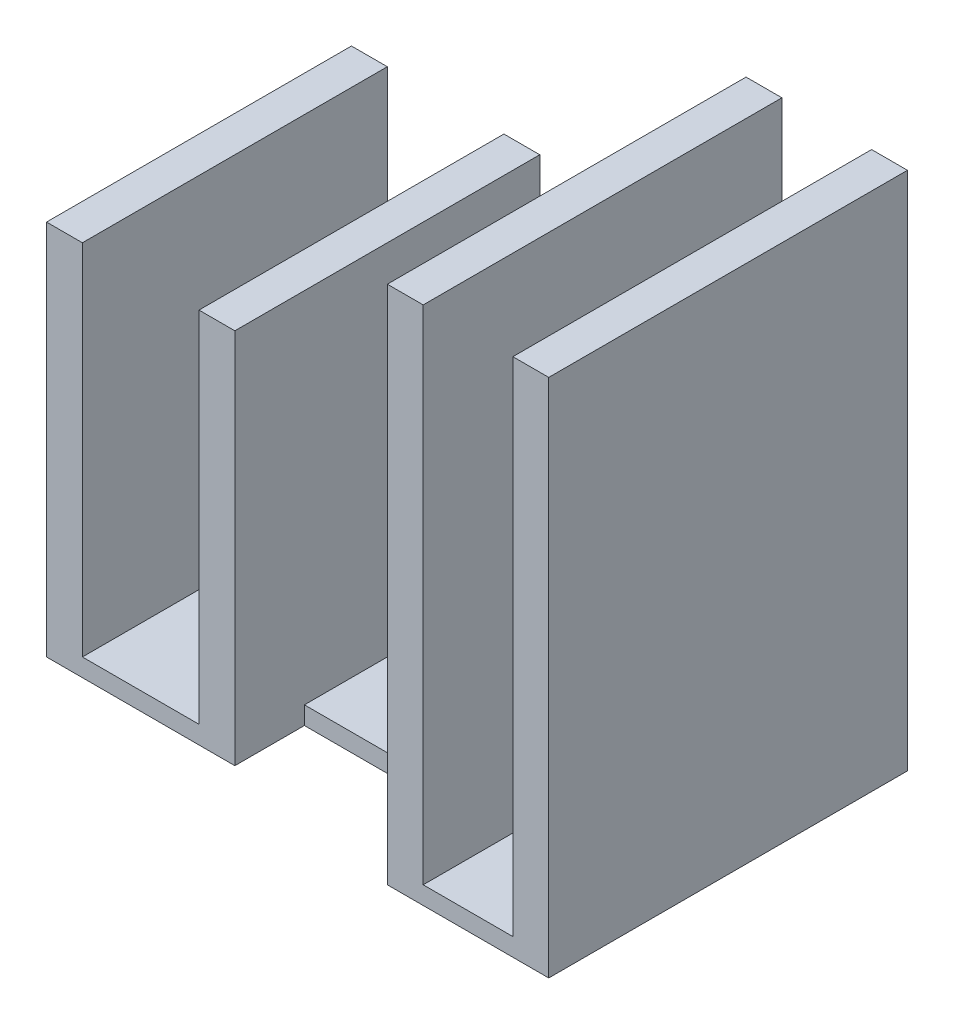
from build123d import *

# Parameters (mm, degrees)
SKETCH1_W           = 2
SKETCH1_H           = 8.5
SKETCH1_H_2         = 20
SKETCH1_H_3         = 17
BOSS_EXTRUDE1_DEPTH = 20
BOSS_EXTRUDE2_DEPTH = 1
SKETCH3_W           = 2
SKETCH3_H           = 20
BOSS_EXTRUDE3_DEPTH = 8


with BuildPart() as part:
    # Sketch1 → Boss-Extrude1 (new body)
    with BuildSketch(Plane(origin=(0, 0, 0), x_dir=(1, 0, 0), z_dir=(0, 1, 0))):
        with Locations((-7.5, 4.25)):
            Rectangle(SKETCH1_W, SKETCH1_H)
        with Locations((-7.5, -4.25)):
            Rectangle(SKETCH1_W, SKETCH1_H)
        with Locations((20, 0)):
            Rectangle(SKETCH1_W, SKETCH1_H_2)
        with Locations((1, 0)):
            Rectangle(SKETCH1_W, SKETCH1_H_3)
        Polygon((14, 10), (14, -10), (12, -10), (12, 0), (12, 10), align=None)
    extrude(amount=BOSS_EXTRUDE1_DEPTH)

    # Sketch2 → Boss-Extrude2 (add)
    with BuildSketch(Plane.XZ):
        Polygon((21, -10), (21, 10), (12, 10), (12, 4.622142766), (2, 4.622142766), (2, 8.5), (-8.5, 8.5), (-8.5, -8.5), (2, -8.5), (2, -3.512828502), (12, -3.512828502), (12, -10), align=None)
    extrude(amount=BOSS_EXTRUDE2_DEPTH)

    # Sketch3 → Boss-Extrude3 (add)
    with BuildSketch(Plane(origin=(0, 20, 0), x_dir=(1, 0, 0), z_dir=(0, 1, 0))):
        with Locations((13, 0)):
            Rectangle(SKETCH3_W, SKETCH3_H)
        with Locations((20, 0)):
            Rectangle(SKETCH3_W, SKETCH3_H)
    extrude(amount=BOSS_EXTRUDE3_DEPTH)


solid = part.part
